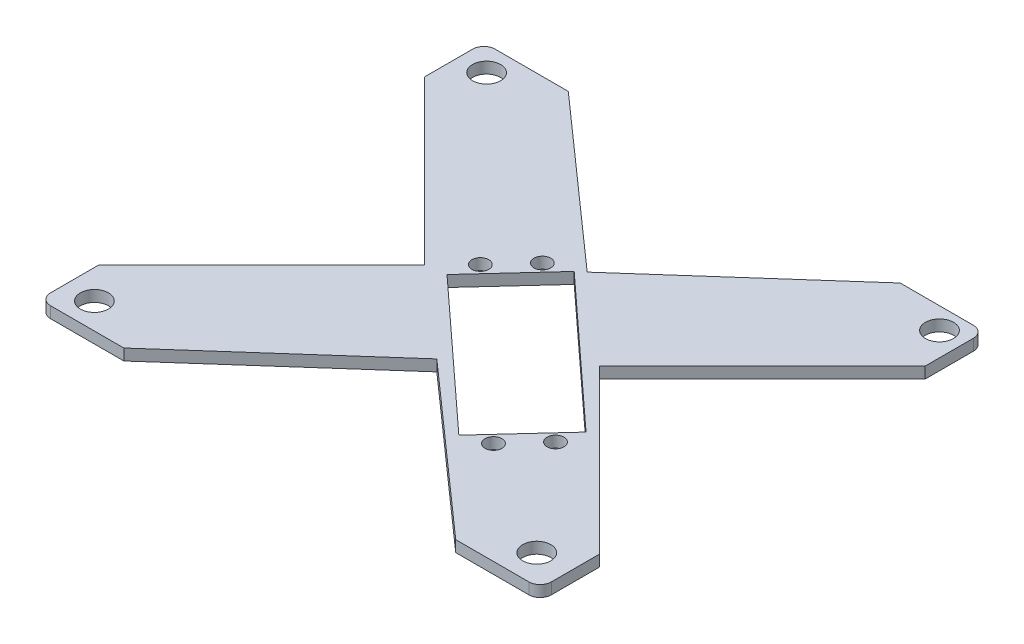
from build123d import *

# Parameters (mm, degrees)
SKETCH2_W           = 113.03
SKETCH2_H           = 100.33
BOSS_EXTRUDE1_DEPTH = 2.54
FILLET1_R           = 2.54
FILLET2_R           = 2.54
CUT_EXTRUDE1_DEPTH  = 3.54
SKETCH5_R           = 3.175
CUT_EXTRUDE2_DEPTH  = 3.54
CUT_EXTRUDE3_DEPTH  = 3.54
SKETCH9_R           = 1.905
CUT_EXTRUDE4_DEPTH  = 5.08


with BuildPart() as part:
    # Sketch2 → Boss-Extrude1 (new body)
    with BuildSketch(Plane(origin=(0, 0, 0), x_dir=(1, 0, 0), z_dir=(0, 1, 0))):
        Rectangle(SKETCH2_W, SKETCH2_H)
    extrude(amount=BOSS_EXTRUDE1_DEPTH)

    # Fillet1
    fillet1_edges = [part.edges().sort_by_distance(p)[0] for p in [
        (-56.515, 1.27, -50.165),
    ]]
    fillet(fillet1_edges, radius=FILLET1_R)

    # Fillet2
    fillet2_edges = [part.edges().sort_by_distance(p)[0] for p in [
        (56.515, 1.27, 50.165),
        (-56.515, 1.27, 50.165),
        (56.515, 1.27, -50.165),
    ]]
    fillet(fillet2_edges, radius=FILLET2_R)

    # Sketch4 → Cut-Extrude1 (cut, through all)
    with BuildSketch(Plane(origin=(0, 2.54, 0), x_dir=(1, 0, 0), z_dir=(0, 1, 0))):
        Polygon((-37.461428175, 50.165), (0, 16.968868313), (37.461428175, 50.165), align=None)
        Polygon((0, -16.968868313), (37.461428175, -50.165), (-37.461428175, -50.165), align=None)
        Polygon((-56.515, 36.721051224), (-19.783044536, -0.01090424), (-56.515, -36.742859704), align=None)
        Polygon((19.783044536, -0.01090424), (56.515, -36.742859704), (56.515, 36.721051224), align=None)
    extrude(amount=-CUT_EXTRUDE1_DEPTH, mode=Mode.SUBTRACT)

    # Sketch5 → Cut-Extrude2 (cut, through all)
    with BuildSketch(Plane(origin=(0, 2.54, 0), x_dir=(1, 0, 0), z_dir=(0, 1, 0))):
        with Locations((-50.345804437, 44.613514098)):
            Circle(SKETCH5_R)
        with Locations((49.165550163, -43.56764163)):
            Circle(SKETCH5_R)
        with Locations((51.157011398, 45.33235837)):
            Circle(SKETCH5_R)
        with Locations((-49.976757123, -44.286485902)):
            Circle(SKETCH5_R)
    extrude(amount=-CUT_EXTRUDE2_DEPTH, mode=Mode.SUBTRACT)

    # Sketch8 → Cut-Extrude3 (cut, through all)
    with BuildSketch(Plane(origin=(0, 2.54, 0), x_dir=(1, 0, 0), z_dir=(0, 1, 0))):
        Polygon((-15.34300557, 0.671713564), (17.39574797, -29.394488667), (31.140297562, -14.428201334), (-1.598455979, 15.638000897), align=None)
    extrude(amount=-CUT_EXTRUDE3_DEPTH, mode=Mode.SUBTRACT)

    # Sketch9 → Cut-Extrude4 (cut)
    with BuildSketch(Plane(origin=(0, 2.54, 0), x_dir=(1, 0, 0), z_dir=(0, 1, 0))):
        with Locations((22.938442662, -27.1142567)):
            Circle(SKETCH9_R)
        with Locations((29.632724368, -19.812515234)):
            Circle(SKETCH9_R)
        with Locations((-13.541882712, 6.388082929)):
            Circle(SKETCH9_R)
        with Locations((-6.83523338, 13.678466371)):
            Circle(SKETCH9_R)
    extrude(amount=-CUT_EXTRUDE4_DEPTH, mode=Mode.SUBTRACT)


solid = part.part
